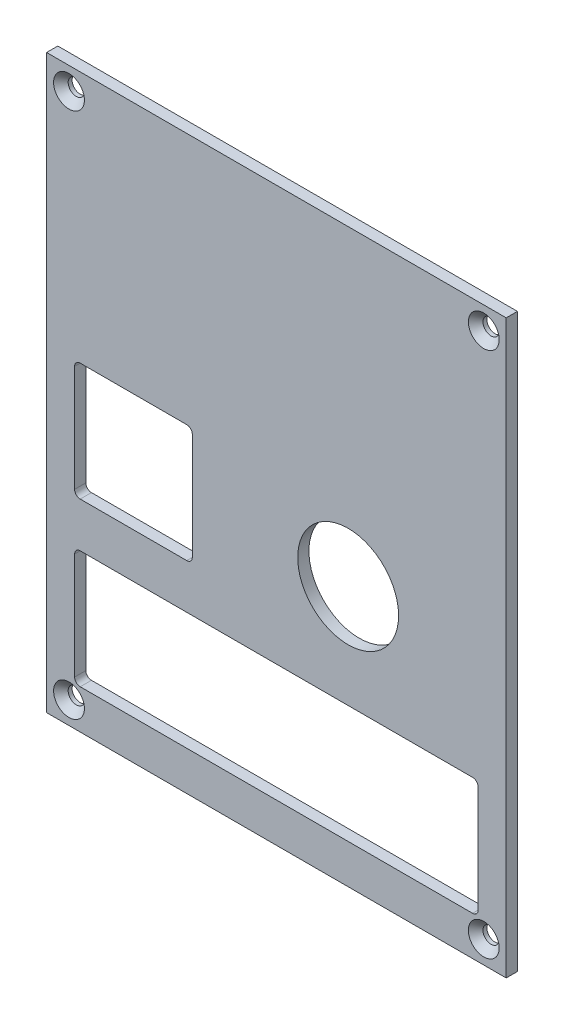
from build123d import *

# Parameters (mm, degrees)
SKETCH1_W                                    = 82
SKETCH1_H                                    = 102
BOSS_EXTRUDE1_DEPTH                          = 2
SKETCH2_R                                    = 9
CUT_EXTRUDE2_DEPTH                           = 2
CSK_FOR_M2_5_COUNTERSUNK_FLAT_HEAD_S_2_COUNT = 2
CSK_FOR_M2_5_COUNTERSUNK_FLAT_HEAD_S_2_PITCH = 94
CSK_FOR_M2_5_COUNTERSUNK_FLAT_HEAD_S_3_COUNT = 2
CSK_FOR_M2_5_COUNTERSUNK_FLAT_HEAD_S_3_PITCH = 119.63277143
CSK_FOR_M2_5_COUNTERSUNK_FLAT_HEAD_S_4_COUNT = 2
CSK_FOR_M2_5_COUNTERSUNK_FLAT_HEAD_S_4_PITCH = 74


with BuildPart() as part:
    # Sketch1 → Boss-Extrude1 (new body)
    with BuildSketch(Plane.XY):
        with Locations((-8.498222994, 4.726902457)):
            Rectangle(SKETCH1_W, SKETCH1_H)
    extrude(amount=BOSS_EXTRUDE1_DEPTH)

    # Sketch2 → Cut-Extrude2 (cut)
    with BuildSketch(Plane.XY.offset(2)):
        with Locations((4.301781638, 0.112195324)):
            Circle(SKETCH2_R)
        with BuildLine():
            Line((-43.498222994, -18.273097543), (26.501777006, -18.273097543))
            ThreePointArc((26.501777006, -18.273097543), (27.208883787, -18.565990762), (27.501777006, -19.273097543))
            Line((27.501777006, -19.273097543), (27.501777006, -38.273097543))
            ThreePointArc((27.501777006, -38.273097543), (27.208883787, -38.980204324), (26.501777006, -39.273097543))
            Line((26.501777006, -39.273097543), (-43.498222994, -39.273097543))
            ThreePointArc((-43.498222994, -39.273097543), (-44.205329775, -38.980204324), (-44.498222994, -38.273097543))
            Line((-44.498222994, -38.273097543), (-44.498222994, -19.273097543))
            ThreePointArc((-44.498222994, -19.273097543), (-44.205329775, -18.565990762), (-43.498222994, -18.273097543))
        make_face()
        with BuildLine():
            Line((-43.498222994, 10.726902457), (-24.498222994, 10.726902457))
            ThreePointArc((-24.498222994, 10.726902457), (-23.791116213, 10.434009238), (-23.498222994, 9.726902457))
            Line((-23.498222994, 9.726902457), (-23.498222994, -9.273097543))
            ThreePointArc((-23.498222994, -9.273097543), (-23.791116213, -9.980204324), (-24.498222994, -10.273097543))
            Line((-24.498222994, -10.273097543), (-43.498222994, -10.273097543))
            ThreePointArc((-43.498222994, -10.273097543), (-44.205329775, -9.980204324), (-44.498222994, -9.273097543))
            Line((-44.498222994, -9.273097543), (-44.498222994, 9.726902457))
            ThreePointArc((-44.498222994, 9.726902457), (-44.205329775, 10.434009238), (-43.498222994, 10.726902457))
        make_face()
    extrude(amount=-CUT_EXTRUDE2_DEPTH, mode=Mode.SUBTRACT)

    # Sketch18 → CSK for M2.5 Countersunk Flat Head Screw2 (revolve, cut)
    with BuildSketch(Plane(origin=(-45.498222994, 51.726902457, 2), x_dir=(0, -1, 0), z_dir=(1, 0, 0))):
        Polygon((0, 0), (0, 2), (1.45, 2), (1.45, 1.3), (2.75, 0), align=None)
    csk_for_m2_5_countersunk_flat_head_screw = revolve(axis=Axis((-45.498222994, 51.726902457, 8.35), (0, 0, -1)), mode=Mode.SUBTRACT)

    # CSK for M2.5 Countersunk Flat Head S 2: CSK for M2.5 Countersunk Flat Head Screw2 ×2
    with Locations(*[(0, -i * CSK_FOR_M2_5_COUNTERSUNK_FLAT_HEAD_S_2_PITCH, 0) for i in range(1, CSK_FOR_M2_5_COUNTERSUNK_FLAT_HEAD_S_2_COUNT)]):
        add(csk_for_m2_5_countersunk_flat_head_screw, mode=Mode.SUBTRACT)

    # CSK for M2.5 Countersunk Flat Head S 3: CSK for M2.5 Countersunk Flat Head Screw2 ×2
    with Locations(*[Vector(0.618559606, -0.785737878, 0) * (i * CSK_FOR_M2_5_COUNTERSUNK_FLAT_HEAD_S_3_PITCH) for i in range(1, CSK_FOR_M2_5_COUNTERSUNK_FLAT_HEAD_S_3_COUNT)]):
        add(csk_for_m2_5_countersunk_flat_head_screw, mode=Mode.SUBTRACT)

    # CSK for M2.5 Countersunk Flat Head S 4: CSK for M2.5 Countersunk Flat Head Screw2 ×2
    with Locations(*[(i * CSK_FOR_M2_5_COUNTERSUNK_FLAT_HEAD_S_4_PITCH, 0, 0) for i in range(1, CSK_FOR_M2_5_COUNTERSUNK_FLAT_HEAD_S_4_COUNT)]):
        add(csk_for_m2_5_countersunk_flat_head_screw, mode=Mode.SUBTRACT)


solid = part.part
